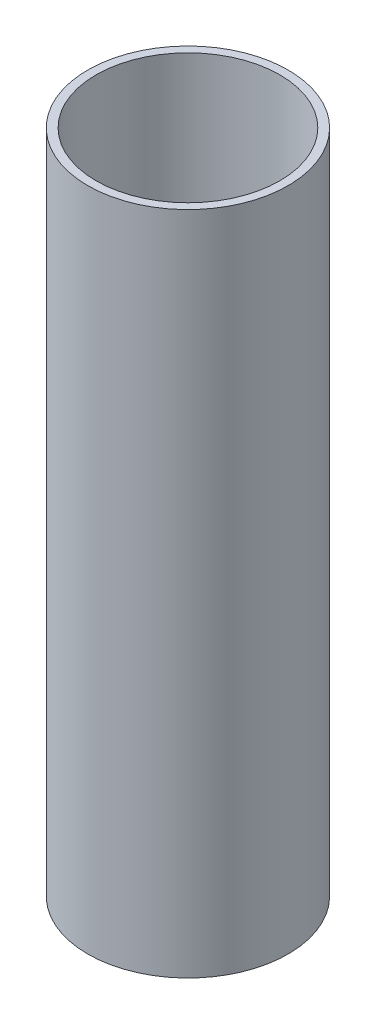
from build123d import *

# Parameters (mm, degrees)
SKETCH1_R           = 38.1
SKETCH1_R_2         = 34.925
BOSS_EXTRUDE1_DEPTH = 253.060427


with BuildPart() as part:
    # Sketch1 → Boss-Extrude1 (new body)
    with BuildSketch(Plane(origin=(0, 0, 0), x_dir=(1, 0, 0), z_dir=(0, 1, 0))):
        Circle(SKETCH1_R)
        Circle(SKETCH1_R_2, mode=Mode.SUBTRACT)
    extrude(amount=BOSS_EXTRUDE1_DEPTH)


solid = part.part
